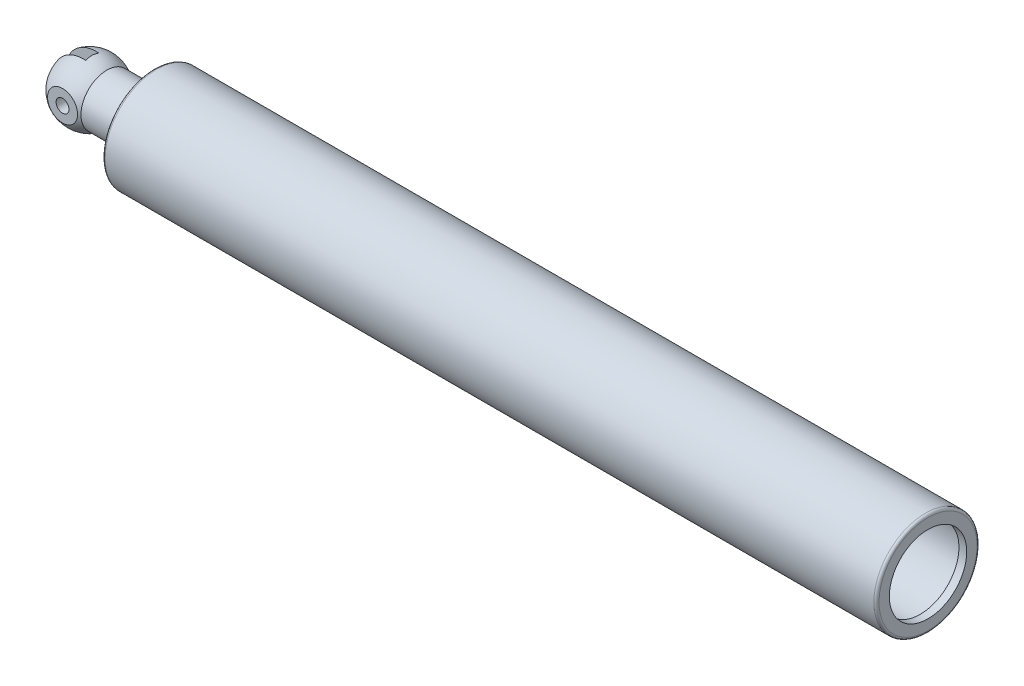
from build123d import *

# Parameters (mm, degrees)
SKETCH6_OUTSIDE_W       = 110.342
SKETCH6_OUTSIDE_H       = 110.342
SKETCH6_OUTSIDE_W_2     = 21
SKETCH6_OUTSIDE_H_2     = 30
CUT_EXTRUDE3_DEPTH      = 40
SKETCH4_W               = 17.5
SKETCH4_H               = 5
FILLET1_R               = 1
SKETCH8_R               = 2.5
CUT_EXTRUDE4_DEPTH      = 10.5
CUT_EXTRUDE4_DEPTH_BACK = 31.5


with BuildPart() as part:
    # Sketch1 → Revolve1 (revolve)
    with BuildSketch(Plane.XY):
        with BuildLine():
            Line((297, 15), (300, 15))
            Line((300, 15), (300, 20))
            Line((300, 20), (0, 20))
            Line((0, 20), (0, 10))
            Line((0, 10), (-18.366750419, 10))
            ThreePointArc((-18.366750419, 10), (-30.674548662, 10.573528147), (-37, 0))
            Line((-37, 0), (0, 0))
            Line((0, 0), (3, 0))
            Line((3, 0), (3, 17))
            Line((3, 17), (297, 17))
            Line((297, 17), (297, 15))
        make_face()
    revolve(axis=Axis((0, 0, 0), (1, 0, 0)))

    # Sketch6 outside → Cut-Extrude3 (cut)
    with BuildSketch(Plane.ZY):
        Rectangle(SKETCH6_OUTSIDE_W, SKETCH6_OUTSIDE_H)
        Rectangle(SKETCH6_OUTSIDE_W_2, SKETCH6_OUTSIDE_H_2, mode=Mode.SUBTRACT)
    extrude(amount=CUT_EXTRUDE3_DEPTH, mode=Mode.SUBTRACT)

    # Sketch4 → Cut-Revolve1 (revolve, cut)
    with BuildSketch(Plane(origin=(0, 0, 0), x_dir=(1, 0, 0), z_dir=(0, 1, 0))):
        with Locations((-28.25, 0)):
            Rectangle(SKETCH4_W, SKETCH4_H)
    revolve(axis=Axis((-37, 0, -2.5), (0, 0, 1)), mode=Mode.SUBTRACT)

    # Fillet1
    fillet1_edges = [part.edges().sort_by_distance(p)[0] for p in [
        (300, -20, 0),
        (0, -10, 0),
        (0, -20, 0),
    ]]
    fillet(fillet1_edges, radius=FILLET1_R)

    # Sketch8 → Cut-Extrude4 (cut, two sides)
    with BuildSketch(Plane.XY.offset(10.5)) as cut_extrude4_sk:
        with Locations((-25, 0)):
            Circle(SKETCH8_R)
    extrude(amount=CUT_EXTRUDE4_DEPTH, mode=Mode.SUBTRACT)
    extrude(cut_extrude4_sk.sketch, amount=-CUT_EXTRUDE4_DEPTH_BACK, mode=Mode.SUBTRACT)


solid = part.part
